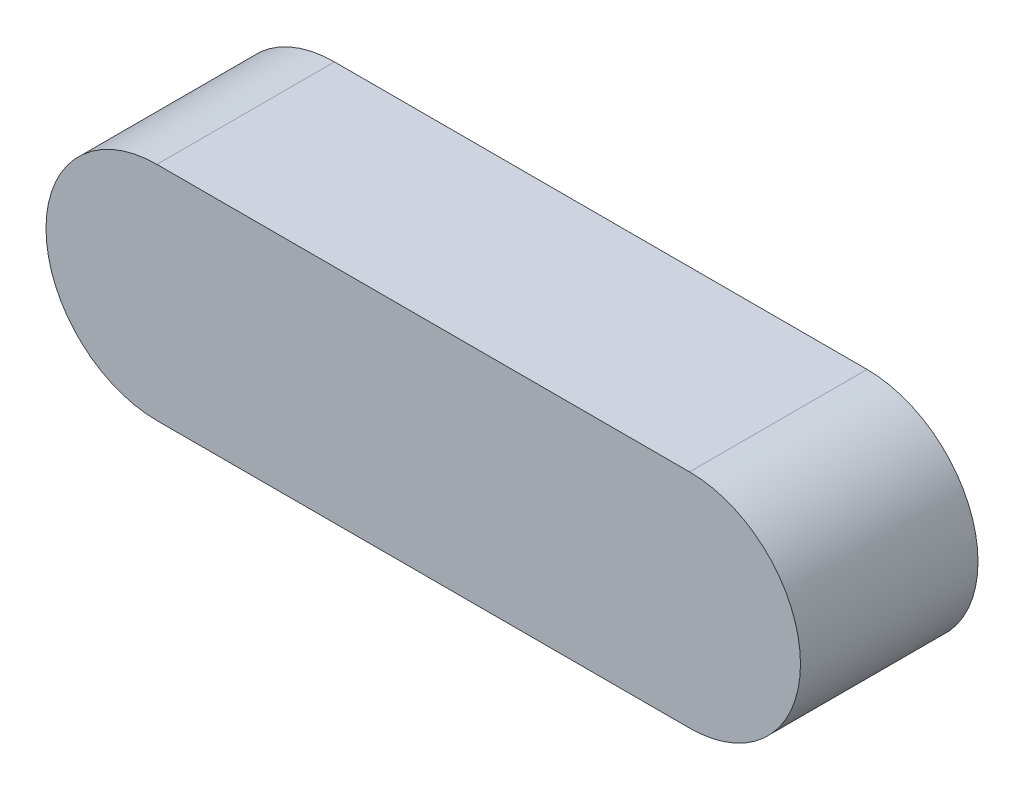
from build123d import *

# Parameters (mm, degrees)
BOSS_EXTRUDE1_DEPTH = 50.8


with BuildPart() as part:
    # Sketch1 → Boss-Extrude1 (new body)
    with BuildSketch(Plane.XY):
        with BuildLine():
            Line((-76.2, 31.75), (76.2, 31.75))
            ThreePointArc((76.2, 31.75), (107.95, 0), (76.2, -31.75))
            Line((76.2, -31.75), (-76.2, -31.75))
            ThreePointArc((-76.2, -31.75), (-107.95, 0), (-76.2, 31.75))
        make_face()
    extrude(amount=BOSS_EXTRUDE1_DEPTH)


solid = part.part
